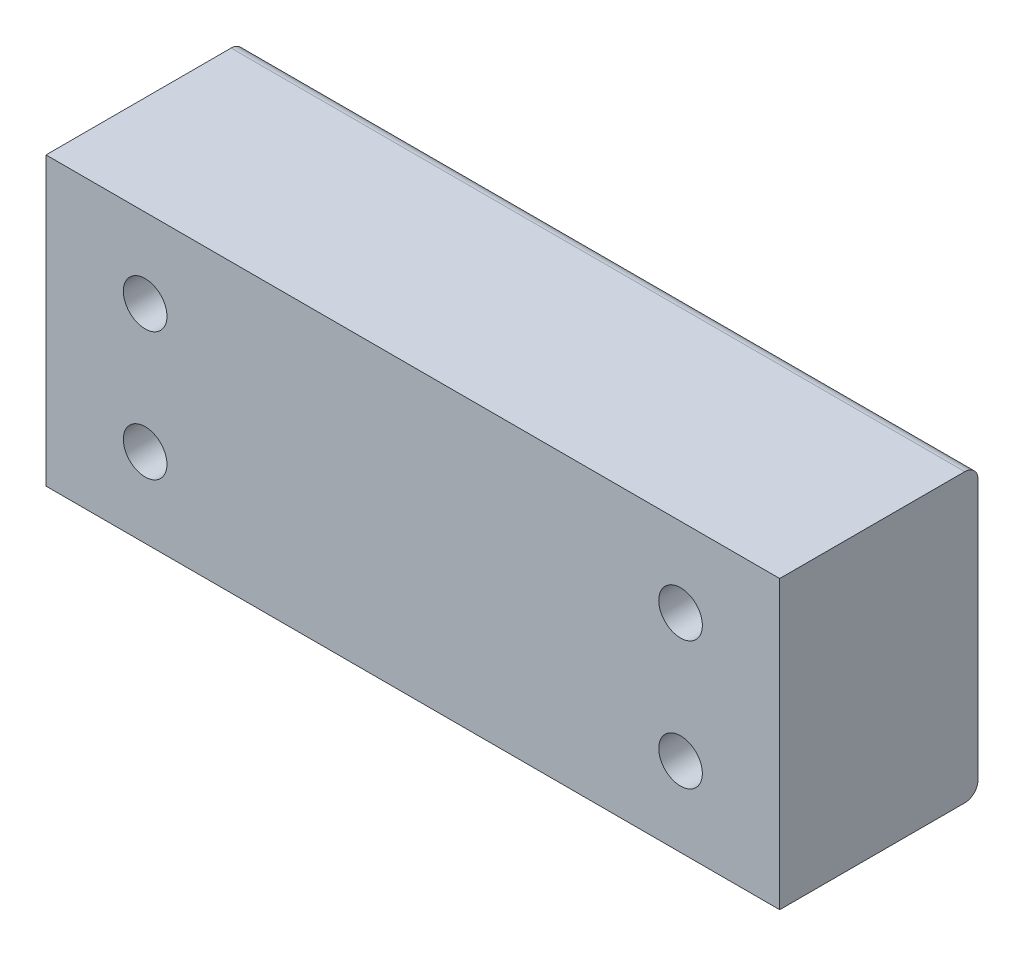
from build123d import *

# Parameters (mm, degrees)
SKETCH1_W           = 55.5
SKETCH1_H           = 21.7
BOSS_EXTRUDE1_DEPTH = 15
SKETCH3_R           = 1.65
CUT_EXTRUDE1_DEPTH  = 16
FILLET1_R           = 1


with BuildPart() as part:
    # Sketch1 → Boss-Extrude1 (new body)
    with BuildSketch(Plane.XY):
        Rectangle(SKETCH1_W, SKETCH1_H)
    extrude(amount=BOSS_EXTRUDE1_DEPTH)

    # Sketch3 → Cut-Extrude1 (cut, through all)
    with BuildSketch(Plane.XY.offset(15)):
        with Locations((-20.25, 4.85)):
            Circle(SKETCH3_R)
        with Locations((-20.25, -4.85)):
            Circle(SKETCH3_R)
        with Locations((20.25, -4.85)):
            Circle(SKETCH3_R)
        with Locations((20.25, 4.85)):
            Circle(SKETCH3_R)
    extrude(amount=-CUT_EXTRUDE1_DEPTH, mode=Mode.SUBTRACT)

    # Fillet1
    fillet1_edges = [part.edges().sort_by_distance(p)[0] for p in [
        (0, -10.85, 0),
        (0, 10.85, 0),
    ]]
    fillet(fillet1_edges, radius=FILLET1_R)


solid = part.part
